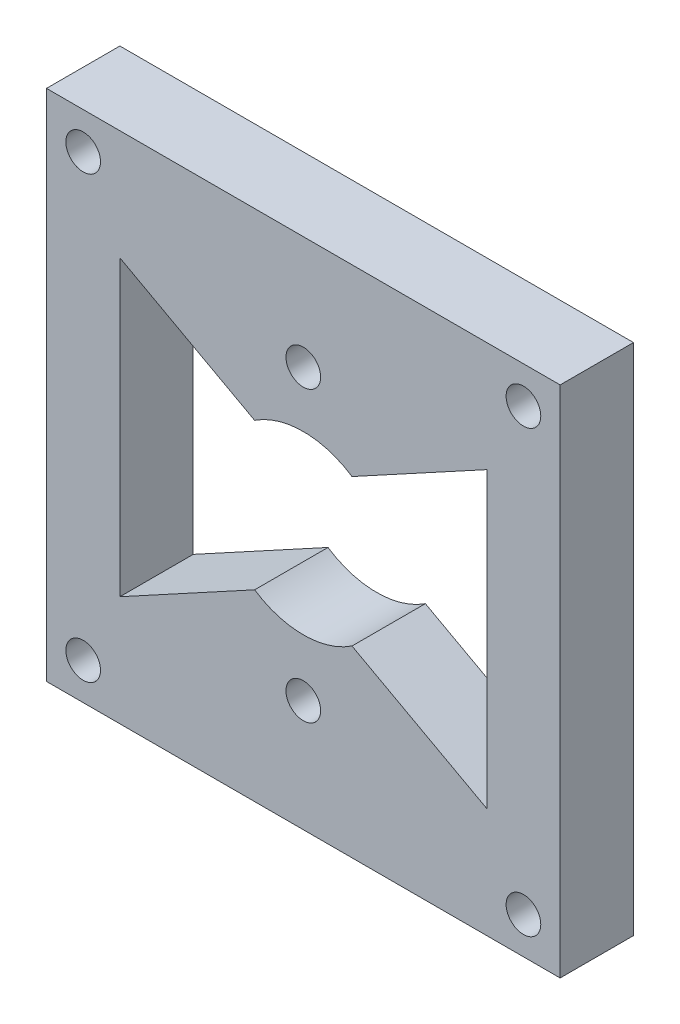
from build123d import *

# Parameters (mm, degrees)
SKETCH1_W           = 44.45
SKETCH1_H           = 44.45
BOSS_EXTRUDE1_DEPTH = 6.35
SKETCH2_R           = 1.5
CUT_EXTRUDE2_DEPTH  = 6.35
SKETCH3_R           = 7.62
CUT_EXTRUDE3_DEPTH  = 6.35
SKETCH4_R           = 1.5
CUT_EXTRUDE4_DEPTH  = 6.35
CUT_EXTRUDE5_DEPTH  = 6.35


with BuildPart() as part:
    # Sketch1 → Boss-Extrude1 (new body)
    with BuildSketch(Plane.XY):
        with Locations((22.225, 22.225)):
            Rectangle(SKETCH1_W, SKETCH1_H)
    extrude(amount=BOSS_EXTRUDE1_DEPTH)

    # Sketch2 → Cut-Extrude2 (cut)
    with BuildSketch(Plane.XY.offset(6.35)):
        with Locations((22.225, 34.671)):
            Circle(SKETCH2_R)
        with Locations((22.225, 9.671)):
            Circle(SKETCH2_R)
    extrude(amount=-CUT_EXTRUDE2_DEPTH, mode=Mode.SUBTRACT)

    # Sketch3 → Cut-Extrude3 (cut)
    with BuildSketch(Plane.XY.offset(6.35)):
        with Locations((22.225, 22.225)):
            Circle(SKETCH3_R)
    extrude(amount=-CUT_EXTRUDE3_DEPTH, mode=Mode.SUBTRACT)

    # Sketch4 → Cut-Extrude4 (cut)
    with BuildSketch(Plane.XY.offset(6.35)):
        with Locations((3.175, 41.275)):
            Circle(SKETCH4_R)
        with Locations((41.275, 41.275)):
            Circle(SKETCH4_R)
        with Locations((41.275, 3.175)):
            Circle(SKETCH4_R)
        with Locations((3.175, 3.175)):
            Circle(SKETCH4_R)
    extrude(amount=-CUT_EXTRUDE4_DEPTH, mode=Mode.SUBTRACT)

    # Sketch7 → Cut-Extrude5 (cut)
    with BuildSketch(Plane.XY.offset(6.35)):
        with BuildLine():
            Line((38.1, 34.925), (38.1, 9.525))
            Line((38.1, 9.525), (26.437113484, 15.875))
            ThreePointArc((26.437113484, 15.875), (29.845, 22.225), (26.437113484, 28.575))
            Line((26.437113484, 28.575), (38.1, 34.925))
        make_face()
        with BuildLine():
            Line((6.35, 9.525), (18.012886516, 15.875))
            ThreePointArc((18.012886516, 15.875), (14.605, 22.225), (18.012886516, 28.575))
            Line((18.012886516, 28.575), (6.35, 34.925))
            Line((6.35, 34.925), (6.35, 9.525))
        make_face()
    extrude(amount=-CUT_EXTRUDE5_DEPTH, mode=Mode.SUBTRACT)


solid = part.part
